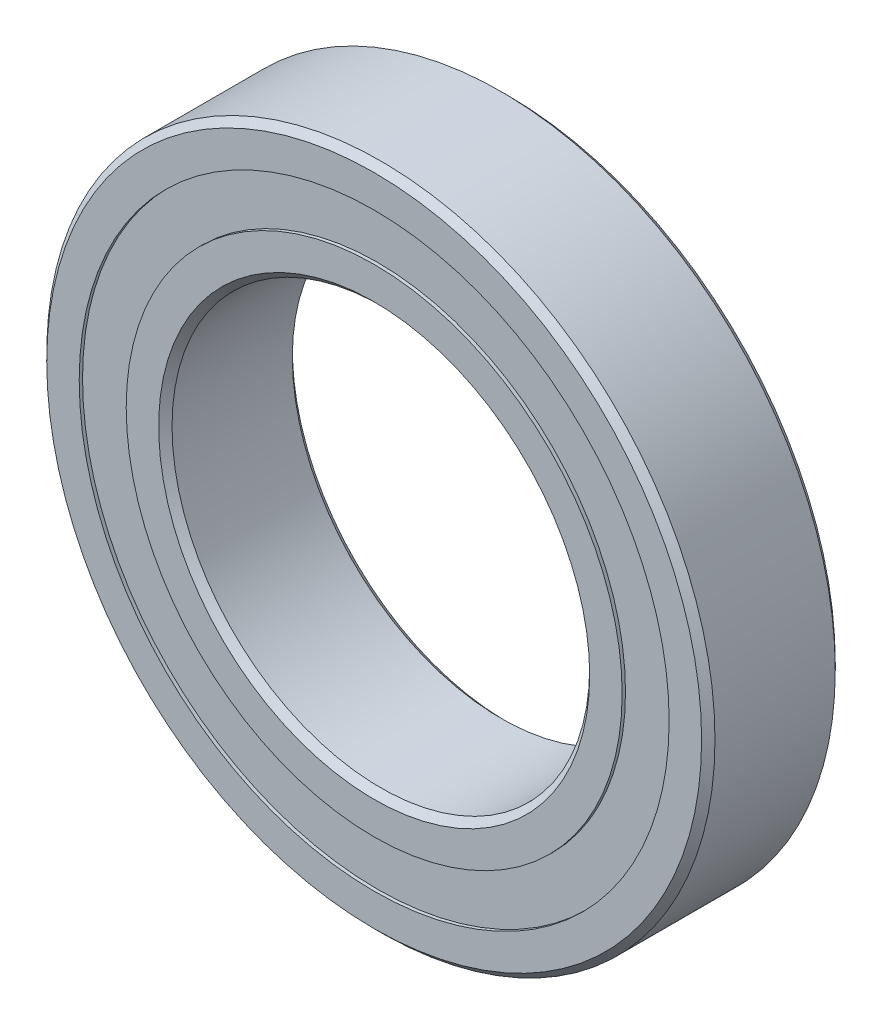
from build123d import *

# Parameters (mm, degrees)
CIRPATTERN1_COUNT = 12
SKETCH5_W         = 3.066127995
SKETCH5_H         = 5.626373626


with BuildPart() as part:
    # Sketch1 → Revolve1 (revolve)
    with BuildSketch(Plane(origin=(0, 0, 0), x_dir=(0, 0, -1), z_dir=(1, 0, 0))):
        with BuildLine():
            Line((7.2, 40), (-7.2, 40))
            Line((-7.2, 40), (-8, 39.2))
            Line((-8, 39.2), (-8, 35.313186813))
            Line((-8, 35.313186813), (-3.555555556, 35.313186813))
            ThreePointArc((-3.555555556, 35.313186813), (0, 37.033872005), (3.555555556, 35.313186813))
            Line((3.555555556, 35.313186813), (8, 35.313186813))
            Line((8, 35.313186813), (8, 39.2))
            Line((8, 39.2), (7.2, 40))
        make_face()
    revolve(axis=Axis((0, 0, 8), (0, 0, -1)))


with BuildPart() as body_2:
    # Sketch3 → Revolve3 (revolve)
    with BuildSketch(Plane(origin=(0, 0, 0), x_dir=(0, 0, -1), z_dir=(1, 0, 0))):
        with BuildLine():
            Line((-8, 29.686813187), (-3.555555556, 29.686813187))
            ThreePointArc((-3.555555556, 29.686813187), (0, 27.966127995), (3.555555556, 29.686813187))
            Line((3.555555556, 29.686813187), (8, 29.686813187))
            Line((8, 29.686813187), (8, 25.8))
            Line((8, 25.8), (7.2, 25))
            Line((7.2, 25), (-7.2, 25))
            Line((-7.2, 25), (-8, 25.8))
            Line((-8, 25.8), (-8, 29.686813187))
        make_face()
    revolve(axis=Axis((0, 0, 8), (0, 0, -1)))


with BuildPart() as body_3:
    # Sketch4 → Revolve4 (revolve)
    with BuildSketch(Plane(origin=(0, 0, 0), x_dir=(0, 0, -1), z_dir=(1, 0, 0))):
        with BuildLine():
            Line((-4.533872005, 32.5), (4.533872005, 32.5))
            ThreePointArc((4.533872005, 32.5), (0, 37.033872005), (-4.533872005, 32.5))
        make_face()
    revolve(axis=Axis((0, 32.5, 4.533872005), (0, 0, -1)))


with BuildPart() as cirpattern1_1:
    # CirPattern1: pattern copy
    add(body_3.part.rotate(Axis((0, 0, -8), (0, 0, 1)), 1 * 360 / CIRPATTERN1_COUNT))


with BuildPart() as cirpattern1_2:
    # CirPattern1: pattern copy
    add(body_3.part.rotate(Axis((0, 0, -8), (0, 0, 1)), 2 * 360 / CIRPATTERN1_COUNT))


with BuildPart() as cirpattern1_3:
    # CirPattern1: pattern copy
    add(body_3.part.rotate(Axis((0, 0, -8), (0, 0, 1)), 3 * 360 / CIRPATTERN1_COUNT))


with BuildPart() as cirpattern1_4:
    # CirPattern1: pattern copy
    add(body_3.part.rotate(Axis((0, 0, -8), (0, 0, 1)), 4 * 360 / CIRPATTERN1_COUNT))


with BuildPart() as cirpattern1_5:
    # CirPattern1: pattern copy
    add(body_3.part.rotate(Axis((0, 0, -8), (0, 0, 1)), 5 * 360 / CIRPATTERN1_COUNT))


with BuildPart() as cirpattern1_6:
    # CirPattern1: pattern copy
    add(body_3.part.rotate(Axis((0, 0, -8), (0, 0, 1)), 6 * 360 / CIRPATTERN1_COUNT))


with BuildPart() as cirpattern1_7:
    # CirPattern1: pattern copy
    add(body_3.part.rotate(Axis((0, 0, -8), (0, 0, 1)), 7 * 360 / CIRPATTERN1_COUNT))


with BuildPart() as cirpattern1_8:
    # CirPattern1: pattern copy
    add(body_3.part.rotate(Axis((0, 0, -8), (0, 0, 1)), 8 * 360 / CIRPATTERN1_COUNT))


with BuildPart() as cirpattern1_9:
    # CirPattern1: pattern copy
    add(body_3.part.rotate(Axis((0, 0, -8), (0, 0, 1)), 9 * 360 / CIRPATTERN1_COUNT))


with BuildPart() as cirpattern1_10:
    # CirPattern1: pattern copy
    add(body_3.part.rotate(Axis((0, 0, -8), (0, 0, 1)), 10 * 360 / CIRPATTERN1_COUNT))


with BuildPart() as cirpattern1_11:
    # CirPattern1: pattern copy
    add(body_3.part.rotate(Axis((0, 0, -8), (0, 0, 1)), 11 * 360 / CIRPATTERN1_COUNT))


with BuildPart() as body_15:
    # Sketch5 → Revolve5 (revolve)
    with BuildSketch(Plane(origin=(0, 0, 0), x_dir=(0, 0, -1), z_dir=(1, 0, 0))):
        with Locations((-6.066936003, 32.5)):
            Rectangle(SKETCH5_W, SKETCH5_H)
        with Locations((6.066936003, 32.5)):
            Rectangle(SKETCH5_W, SKETCH5_H)
    revolve(axis=Axis((0, 0, 8), (0, 0, -1)))


solid = Compound([part.part, body_2.part, body_3.part, cirpattern1_1.part, cirpattern1_2.part, cirpattern1_3.part, cirpattern1_4.part, cirpattern1_5.part, cirpattern1_6.part, cirpattern1_7.part, cirpattern1_8.part, cirpattern1_9.part, cirpattern1_10.part, cirpattern1_11.part, body_15.part])
